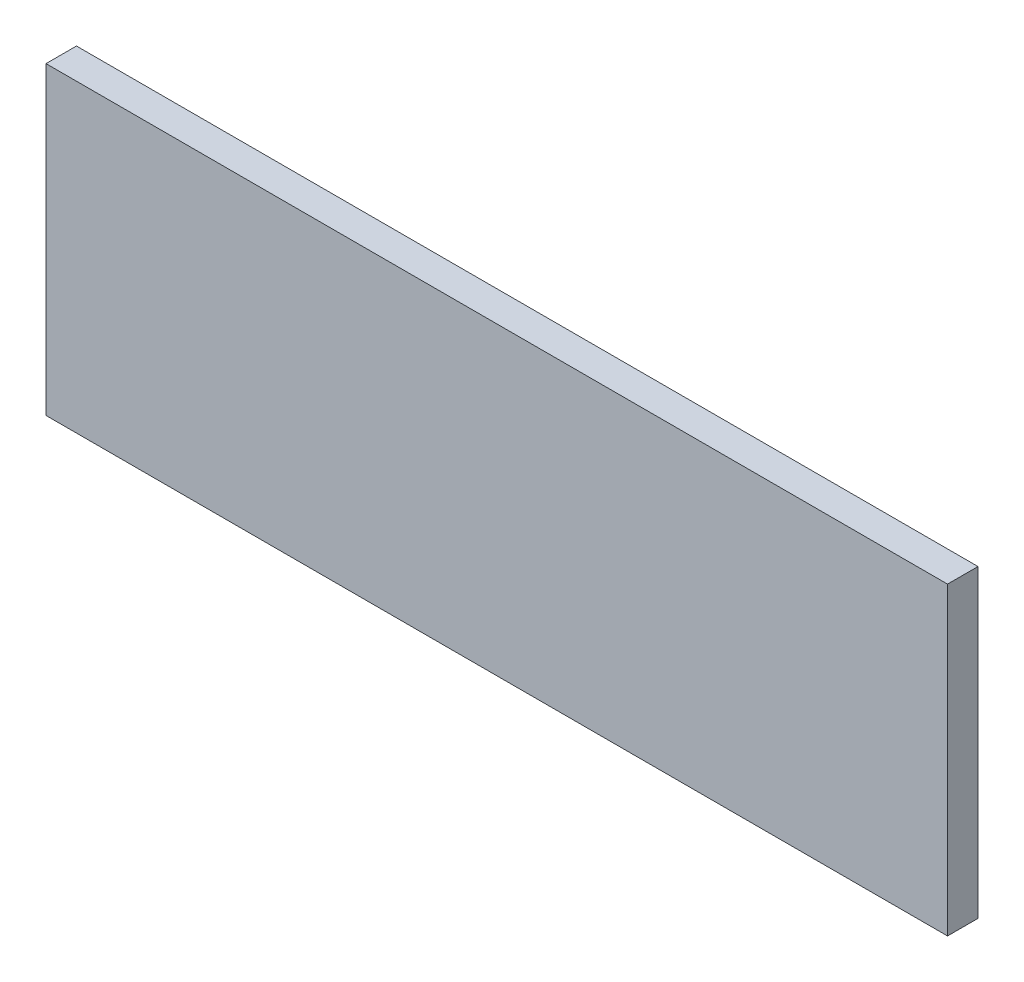
from build123d import *

# Parameters (mm, degrees)
ESQUISSE1_W        = 88.75
ESQUISSE1_H        = 30
BOSS_EXTRU_1_DEPTH = 3


with BuildPart() as part:
    # Esquisse1 → Boss.-Extru.1 (new body)
    with BuildSketch(Plane.XY):
        with Locations((44.375, -15)):
            Rectangle(ESQUISSE1_W, ESQUISSE1_H)
    extrude(amount=BOSS_EXTRU_1_DEPTH)


solid = part.part
